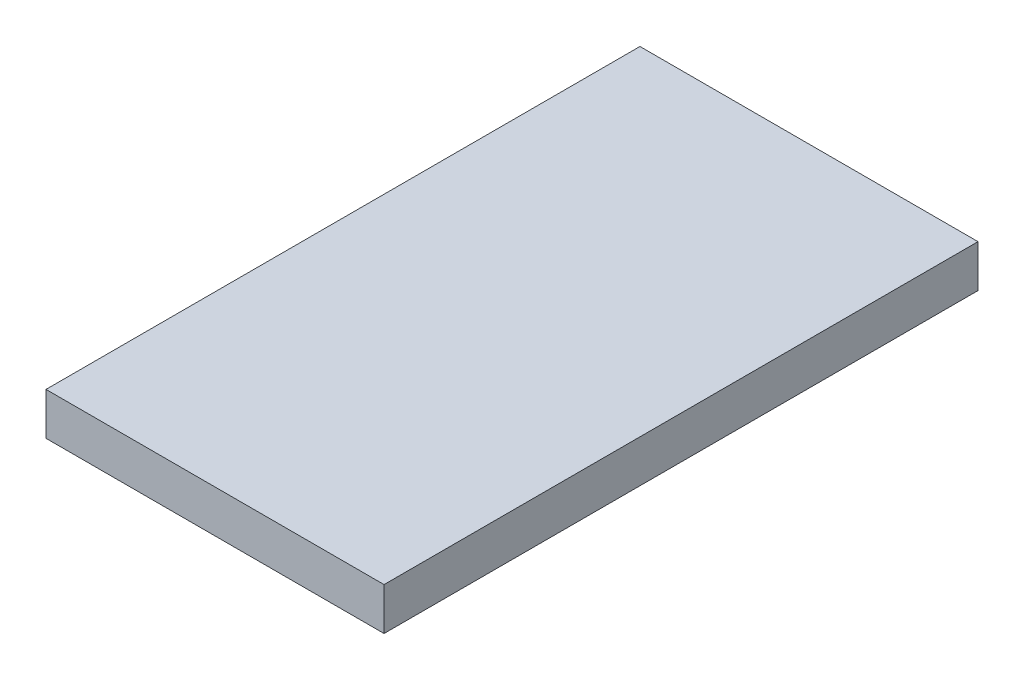
from build123d import *

# Parameters (mm, degrees)
SKETCH1_W           = 167.418688723
SKETCH1_H           = 294.153134808
BOSS_EXTRUDE1_DEPTH = 21


with BuildPart() as part:
    # Sketch1 → Boss-Extrude1 (new body)
    with BuildSketch(Plane(origin=(0, 0, 0), x_dir=(1, 0, 0), z_dir=(0, 1, 0))):
        with Locations((83.709344362, 147.076567404)):
            Rectangle(SKETCH1_W, SKETCH1_H)
    extrude(amount=BOSS_EXTRUDE1_DEPTH)


solid = part.part
